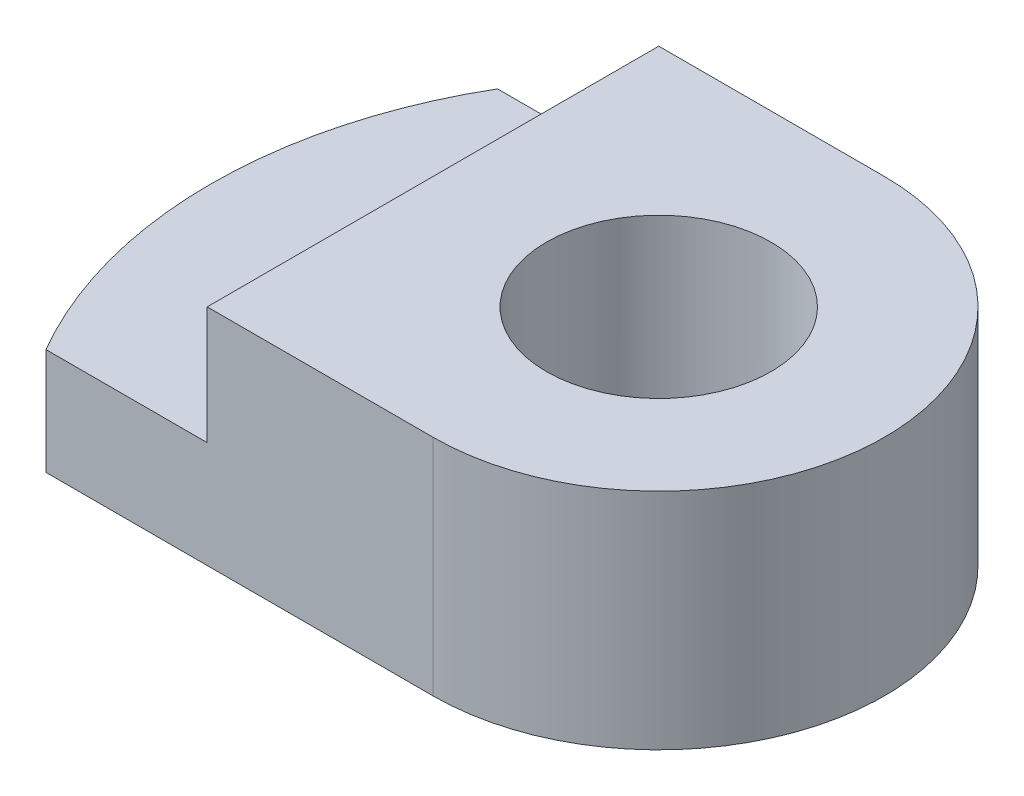
from build123d import *

# Parameters (mm, degrees)
SKETCH1_R               = 38.1
SKETCH1_R_2             = 9.546666028
BOSS_EXTRUDE1_DEPTH     = 38.1
SKETCH2_W               = 38.1
SKETCH2_H               = 19.05
CUT_EXTRUDE1_DEPTH      = 144.78
CUT_EXTRUDE2_DEPTH      = 22.86
CUT_EXTRUDE2_DEPTH_BACK = 20.32
SKETCH5_W               = 40.342749465
SKETCH5_H               = 23.10958947
CUT_EXTRUDE4_DEPTH      = 53.594
CUT_EXTRUDE5_DEPTH      = 10


with BuildPart() as part:
    # Sketch1 → Boss-Extrude1 (new body)
    with BuildSketch(Plane(origin=(0, 0, 0), x_dir=(1, 0, 0), z_dir=(0, 1, 0))):
        Circle(SKETCH1_R)
        Circle(SKETCH1_R_2, mode=Mode.SUBTRACT)
    extrude(amount=BOSS_EXTRUDE1_DEPTH)

    # Sketch2 → Cut-Extrude1 (cut)
    with BuildSketch(Plane.XY.offset(38.1)):
        with Locations((19.05, 9.525)):
            Rectangle(SKETCH2_W, SKETCH2_H)
    extrude(amount=-CUT_EXTRUDE1_DEPTH, mode=Mode.SUBTRACT)

    # Sketch3 → Cut-Extrude2 (cut, two sides)
    with BuildSketch(Plane.XZ.offset(-19.05)) as cut_extrude2_sk:
        with BuildLine():
            Line((0, -19.2), (-32.908509538, -19.2))
            ThreePointArc((-32.908509538, -19.2), (38.1, 0), (-32.908509538, 19.2))
            Line((-32.908509538, 19.2), (0, 19.2))
            ThreePointArc((0, 19.2), (19.2, 0), (0, -19.2))
        make_face()
    extrude(amount=CUT_EXTRUDE2_DEPTH, mode=Mode.SUBTRACT)
    extrude(cut_extrude2_sk.sketch, amount=-CUT_EXTRUDE2_DEPTH_BACK, mode=Mode.SUBTRACT)

    # Sketch5 → Cut-Extrude4 (cut)
    with BuildSketch(Plane.XY.offset(19.2)):
        with Locations((-20.171374733, 7.495205265)):
            Rectangle(SKETCH5_W, SKETCH5_H)
    extrude(amount=-CUT_EXTRUDE4_DEPTH, mode=Mode.SUBTRACT)

    # Sketch6 → Cut-Extrude5 (cut)
    with BuildSketch(Plane(origin=(0, 38.1, 0), x_dir=(1, 0, 0), z_dir=(0, 1, 0))):
        with BuildLine():
            Line((-19.2, 19.2), (-19.2, -19.2))
            Line((-19.2, -19.2), (-32.908509538, -19.2))
            ThreePointArc((-32.908509538, -19.2), (-38.1, 0), (-32.908509538, 19.2))
            Line((-32.908509538, 19.2), (-19.2, 19.2))
        make_face()
    extrude(amount=-CUT_EXTRUDE5_DEPTH, mode=Mode.SUBTRACT)


solid = part.part
